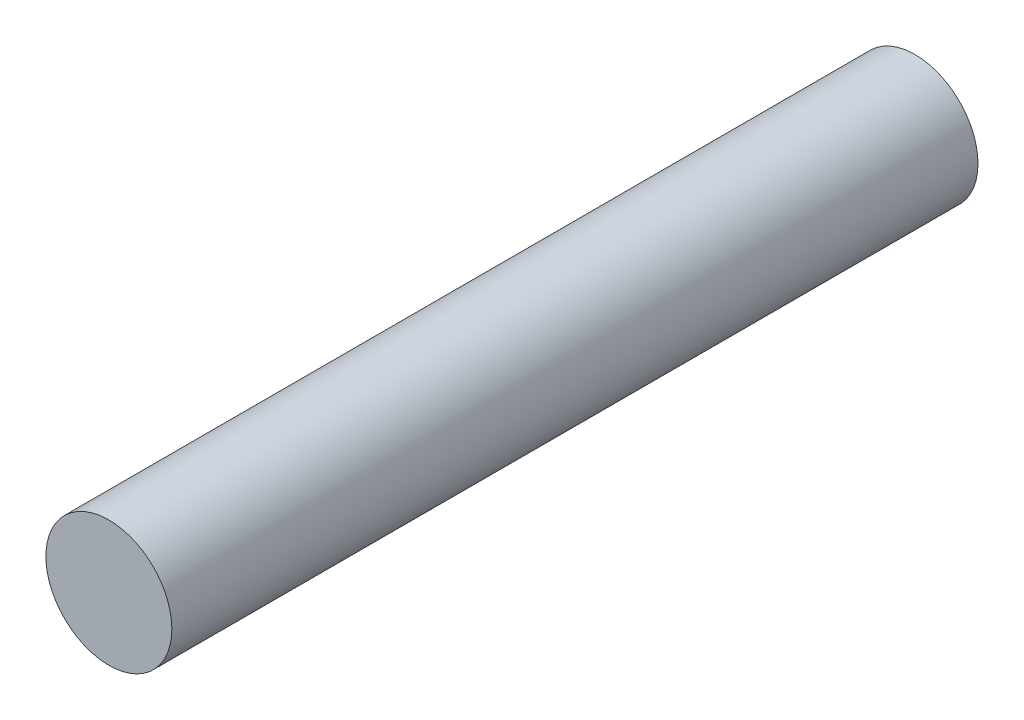
from build123d import *

# Parameters (mm, degrees)
SKETCH1_R           = 3.96875
BOSS_EXTRUDE1_DEPTH = 25.4


with BuildPart() as part:
    # Sketch1 → Boss-Extrude1 (new body, symmetric)
    with BuildSketch(Plane.XY):
        Circle(SKETCH1_R)
    extrude(amount=BOSS_EXTRUDE1_DEPTH, both=True)


solid = part.part
